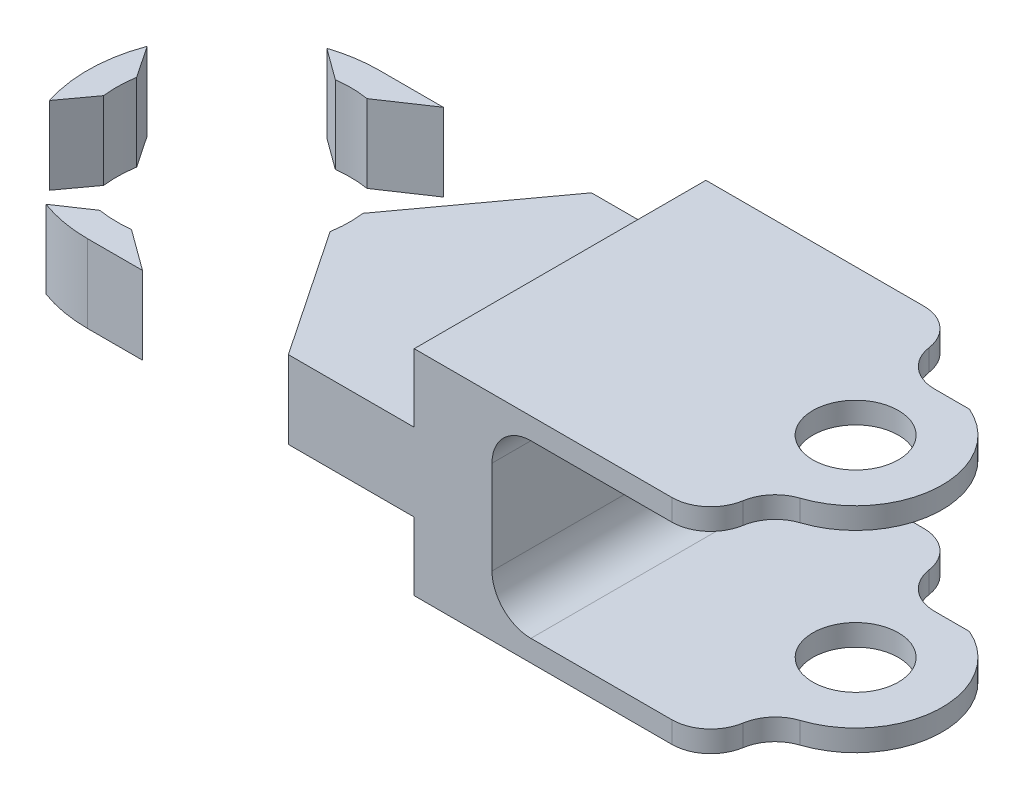
from build123d import *

# Parameters (mm, degrees)
SKETCH1_R           = 3.175
SKETCH1_R_2         = 2.794
BOSS_EXTRUDE1_DEPTH = 13.97
SKETCH4_W           = 16.540015352
SKETCH4_H           = 11.176
SKETCH4_W_2         = 14.224
SKETCH4_W_3         = 21.336
SKETCH4_H_2         = 4.445
SKETCH4_W_4         = 9.525
CUT_EXTRUDE1_DEPTH  = 20.05
SKETCH5_W           = 19.401373877
SKETCH5_H           = 12.180650093
CUT_EXTRUDE2_DEPTH  = 14.97
CUT_EXTRUDE3_DEPTH  = 14.97
FILLET1_R           = 2.54
FILLET2_R           = 2.54
FILLET3_R           = 2.54
FILLET4_R           = 2.54
FILLET5_R           = 2.54
FILLET6_R           = 2.54
SKETCH7_R           = 7.62
SKETCH7_R_2         = 4.572
SKETCH7_R_3         = 3.175
CUT_EXTRUDE4_DEPTH  = 5.08
FILLET7_R           = 2.54
FILLET8_R           = 2.54


with BuildPart() as part:
    # Sketch1 → Boss-Extrude1 (new body)
    with BuildSketch(Plane(origin=(0, 0, 0), x_dir=(1, 0, 0), z_dir=(0, 1, 0))):
        with BuildLine():
            Line((0, 9.525), (40.64, 9.525))
            ThreePointArc((40.64, 9.525), (50.165, 0), (40.64, -9.525))
            Line((40.64, -9.525), (0, -9.525))
            ThreePointArc((0, -9.525), (-9.525, 0), (0, 9.525))
        make_face()
        Circle(SKETCH1_R, mode=Mode.SUBTRACT)
        with Locations((40.64, 0)):
            Circle(SKETCH1_R_2, mode=Mode.SUBTRACT)
    extrude(amount=BOSS_EXTRUDE1_DEPTH)

    # Sketch4 → Cut-Extrude1 (cut, through all)
    with BuildSketch(Plane.XY.offset(9.525)):
        with Locations((48.910007676, 6.985)):
            Rectangle(SKETCH4_W, SKETCH4_H)
        with Locations((33.528, 6.985)):
            Rectangle(SKETCH4_W_2, SKETCH4_H)
        with Locations((10.668, 2.2225)):
            Rectangle(SKETCH4_W_3, SKETCH4_H_2)
        with Locations((-4.7625, 2.2225)):
            Rectangle(SKETCH4_W_4, SKETCH4_H_2)
        with Locations((10.668, 11.7475)):
            Rectangle(SKETCH4_W_3, SKETCH4_H_2)
        with Locations((-4.7625, 11.7475)):
            Rectangle(SKETCH4_W_4, SKETCH4_H_2)
    extrude(amount=-CUT_EXTRUDE1_DEPTH, mode=Mode.SUBTRACT)

    # Sketch5 → Cut-Extrude2 (cut, through all)
    with BuildSketch(Plane(origin=(0, 0, 0), x_dir=(-1, 0, 0), z_dir=(0, -1, 0))):
        with Locations((-47.75918095, 11.276013422)):
            Rectangle(SKETCH5_W, SKETCH5_H)
    extrude(amount=-CUT_EXTRUDE2_DEPTH, mode=Mode.SUBTRACT)

    # Sketch6 → Cut-Extrude3 (cut, through all)
    with BuildSketch(Plane(origin=(0, 13.97, 0), x_dir=(1, 0, 0), z_dir=(0, 1, 0))):
        with BuildLine():
            ThreePointArc((46.2915, 0), (44.636213974, -3.996213974), (40.64, -5.6515))
            Line((40.64, -5.6515), (40.64, -9.525))
            ThreePointArc((40.64, -9.525), (49.010164478, -4.545984119), (48.629634602, 5.185688375))
            Line((48.629634602, 5.185688375), (42.886795123, 5.185688375))
            ThreePointArc((42.886795123, 5.185688375), (45.364257343, 3.101748669), (46.2915, 0))
        make_face()
    extrude(amount=-CUT_EXTRUDE3_DEPTH, mode=Mode.SUBTRACT)

    # Fillet1
    fillet1_edges = [part.edges().sort_by_distance(p)[0] for p in [
        (40.64, 13.2715, 5.6515),
    ]]
    fillet(fillet1_edges, radius=FILLET1_R)

    # Fillet2
    fillet2_edges = [part.edges().sort_by_distance(p)[0] for p in [
        (40.64, 13.2715, 9.525),
    ]]
    fillet(fillet2_edges, radius=FILLET2_R)

    # Fillet3
    fillet3_edges = [part.edges().sort_by_distance(p)[0] for p in [
        (40.64, 0.6985, 5.6515),
    ]]
    fillet(fillet3_edges, radius=FILLET3_R)

    # Fillet4
    fillet4_edges = [part.edges().sort_by_distance(p)[0] for p in [
        (40.64, 0.6985, 9.525),
    ]]
    fillet(fillet4_edges, radius=FILLET4_R)

    # Fillet5
    fillet5_edges = [part.edges().sort_by_distance(p)[0] for p in [
        (38.058494011, 0.6985, -5.185688375),
        (38.058494011, 13.2715, -5.185688375),
    ]]
    fillet(fillet5_edges, radius=FILLET5_R)

    # Fillet6
    fillet6_edges = [part.edges().sort_by_distance(p)[0] for p in [
        (38.058494011, 0.6985, -9.525),
        (38.058494011, 13.2715, -9.525),
    ]]
    fillet(fillet6_edges, radius=FILLET6_R)

    # Sketch7 → Cut-Extrude4 (cut)
    with BuildSketch(Plane.XZ.offset(-4.445)):
        Circle(SKETCH7_R)
        Circle(SKETCH7_R_2, mode=Mode.SUBTRACT)
        Circle(SKETCH7_R_2)
        Circle(SKETCH7_R_3, mode=Mode.SUBTRACT)
        with BuildLine():
            Line((2.168350381, 8.48573984), (0.909617415, 7.565513608))
            ThreePointArc((0.909617415, 7.565513608), (5.281112414, 5.493109472), (7.523875786, 1.206521096))
            Line((7.523875786, 1.206521096), (8.393874448, 2.500479103))
            Line((8.393874448, 2.500479103), (13.116843625, 9.525))
            Line((13.116843625, 9.525), (3.589904102, 9.525))
            Line((3.589904102, 9.525), (2.168350381, 8.48573984))
        make_face()
        with BuildLine():
            Line((8.48573984, -2.168350381), (7.565513608, -0.909617415))
            ThreePointArc((7.565513608, -0.909617415), (5.493109472, -5.281112414), (1.206521096, -7.523875786))
            Line((1.206521096, -7.523875786), (2.500479103, -8.393874448))
            Line((2.500479103, -8.393874448), (4.182813833, -9.525))
            Line((4.182813833, -9.525), (13.863990937, -9.525))
            Line((13.863990937, -9.525), (8.48573984, -2.168350381))
        make_face()
        with BuildLine():
            Line((-8.393874448, -2.500479103), (-8.933786454, -3.303495813))
            ThreePointArc((-8.933786454, -3.303495813), (-6.601390518, -6.866386839), (-2.949506801, -9.056822546))
            Line((-2.949506801, -9.056822546), (-2.168350381, -8.48573984))
            Line((-2.168350381, -8.48573984), (-0.909617415, -7.565513608))
            ThreePointArc((-0.909617415, -7.565513608), (-5.281112414, -5.493109472), (-7.523875786, -1.206521096))
            Line((-7.523875786, -1.206521096), (-8.393874448, -2.500479103))
        make_face()
        with BuildLine():
            Line((-1.206521096, 7.523875786), (-2.500479103, 8.393874448))
            Line((-2.500479103, 8.393874448), (-3.303495813, 8.933786454))
            ThreePointArc((-3.303495813, 8.933786454), (-6.866386839, 6.601390518), (-9.056822546, 2.949506801))
            Line((-9.056822546, 2.949506801), (-8.48573984, 2.168350381))
            Line((-8.48573984, 2.168350381), (-7.565513608, 0.909617415))
            ThreePointArc((-7.565513608, 0.909617415), (-5.493109472, 5.281112414), (-1.206521096, 7.523875786))
        make_face()
    extrude(amount=-CUT_EXTRUDE4_DEPTH, mode=Mode.SUBTRACT)

    # Fillet7
    fillet7_edges = [part.edges().sort_by_distance(p)[0] for p in [
        (26.416, 12.573, 0),
    ]]
    fillet(fillet7_edges, radius=FILLET7_R)

    # Fillet8
    fillet8_edges = [part.edges().sort_by_distance(p)[0] for p in [
        (26.416, 1.397, 0),
    ]]
    fillet(fillet8_edges, radius=FILLET8_R)


solid = part.part
